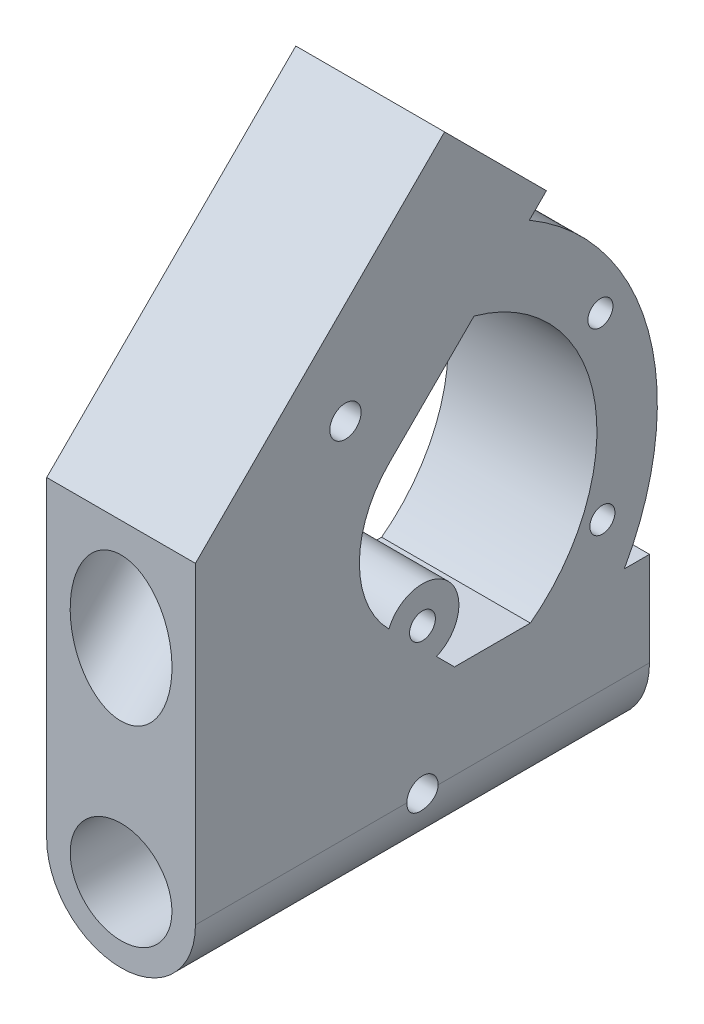
from build123d import *

# Parameters (mm, degrees)
CROQUIS1_R              = 6.5
SALIENTE_EXTRUIR1_DEPTH = 29
SALIENTE_EXTRUIR2_DEPTH = 9.5
CROQUIS3_R              = 6.5
CORTAR_EXTRUIR1_DEPTH   = 73
SALIENTE_EXTRUIR3_DEPTH = 9.5
CROQUIS5_R              = 4.65
CROQUIS5_R_2            = 1.65
SALIENTE_EXTRUIR4_DEPTH = 9.5
CROQUIS6_R              = 1.6
CORTAR_EXTRUIR2_DEPTH   = 15
CROQUIS7_R              = 2
CORTAR_EXTRUIR3_DEPTH   = 26.5


with BuildPart() as part:
    # Croquis1 → Saliente-Extruir1 (new body, symmetric)
    with BuildSketch(Plane.XY):
        with BuildLine():
            Line((-9.5, 12), (9.5, 12))
            Line((9.5, 12), (9.5, 0))
            ThreePointArc((9.5, 0), (0, -9.5), (-9.5, 0))
            Line((-9.5, 0), (-9.5, 12))
        make_face()
        Circle(CROQUIS1_R, mode=Mode.SUBTRACT)
    extrude(amount=SALIENTE_EXTRUIR1_DEPTH, both=True)

    # Croquis2 → Saliente-Extruir2 (add, symmetric)
    with BuildSketch(Plane(origin=(0, 0, 0), x_dir=(0, 0, -1), z_dir=(1, 0, 0))):
        with BuildLine():
            Line((-29, 12), (-29, 40))
            Line((-29, 40), (2.819805153, 71.819805153))
            Line((2.819805153, 71.819805153), (15.830569927, 58.80904038))
            Line((15.830569927, 58.80904038), (-4.251796904, 38.726673548))
            ThreePointArc((-4.251796904, 38.726673548), (-8.059408749, 29.534285393), (-4.251796904, 20.341897237))
            Line((-4.251796904, 20.341897237), (4.090100333, 12))
            Line((4.090100333, 12), (-29, 12))
        make_face()
    extrude(amount=SALIENTE_EXTRUIR2_DEPTH, both=True)

    # Croquis3 → Cortar-Extruir1 (cut)
    with BuildSketch(Plane(origin=(0, 37.319805153, -37.319805153), x_dir=(1, 0, 0), z_dir=(0, 0.707106781, -0.707106781))):
        with Locations((0, -39.590367902)):
            Circle(CROQUIS3_R)
    extrude(amount=-CORTAR_EXTRUIR1_DEPTH, mode=Mode.SUBTRACT)

    # Croquis4 → Saliente-Extruir3 (add, symmetric)
    with BuildSketch(Plane(origin=(0, 0, 0), x_dir=(0, 0, -1), z_dir=(1, 0, 0))):
        with BuildLine():
            Line((6.58232419, 49.560794642), (13.653392001, 56.631862454))
            ThreePointArc((13.653392001, 56.631862454), (28.845023505, 36.796295198), (25.782485256, 12))
            Line((25.782485256, 12), (13.782485256, 12))
            ThreePointArc((13.782485256, 12), (21.90502045, 33.027546833), (6.58232419, 49.560794642))
        make_face()
    extrude(amount=SALIENTE_EXTRUIR3_DEPTH, both=True)

    # Croquis5 → Saliente-Extruir4 (add, symmetric)
    with BuildSketch(Plane(origin=(0, 0, 0), x_dir=(0, 0, -1), z_dir=(1, 0, 0))):
        with Locations((0, 18.59255238)):
            Circle(CROQUIS5_R)
        with Locations((0, 18.59255238)):
            Circle(CROQUIS5_R_2, mode=Mode.SUBTRACT)
    extrude(amount=SALIENTE_EXTRUIR4_DEPTH, both=True)

    # Croquis6 → Cortar-Extruir2 (cut, symmetric)
    with BuildSketch(Plane(origin=(0, 0, 0), x_dir=(0, 0, -1), z_dir=(1, 0, 0))):
        with Locations((22.726275042, 41.82542613)):
            Circle(CROQUIS6_R)
        with Locations((22.98, 18.84542613)):
            Circle(CROQUIS6_R)
    extrude(amount=CORTAR_EXTRUIR2_DEPTH, both=True, mode=Mode.SUBTRACT)

    # Croquis7 → Cortar-Extruir3 (cut, symmetric)
    with BuildSketch(Plane(origin=(0, 0, 0), x_dir=(0, 0, -1), z_dir=(1, 0, 0))):
        Circle(CROQUIS7_R)
        with Locations((-9.83740623, 46.151828996)):
            Circle(CROQUIS7_R)
    extrude(amount=CORTAR_EXTRUIR3_DEPTH, both=True, mode=Mode.SUBTRACT)


solid = part.part
